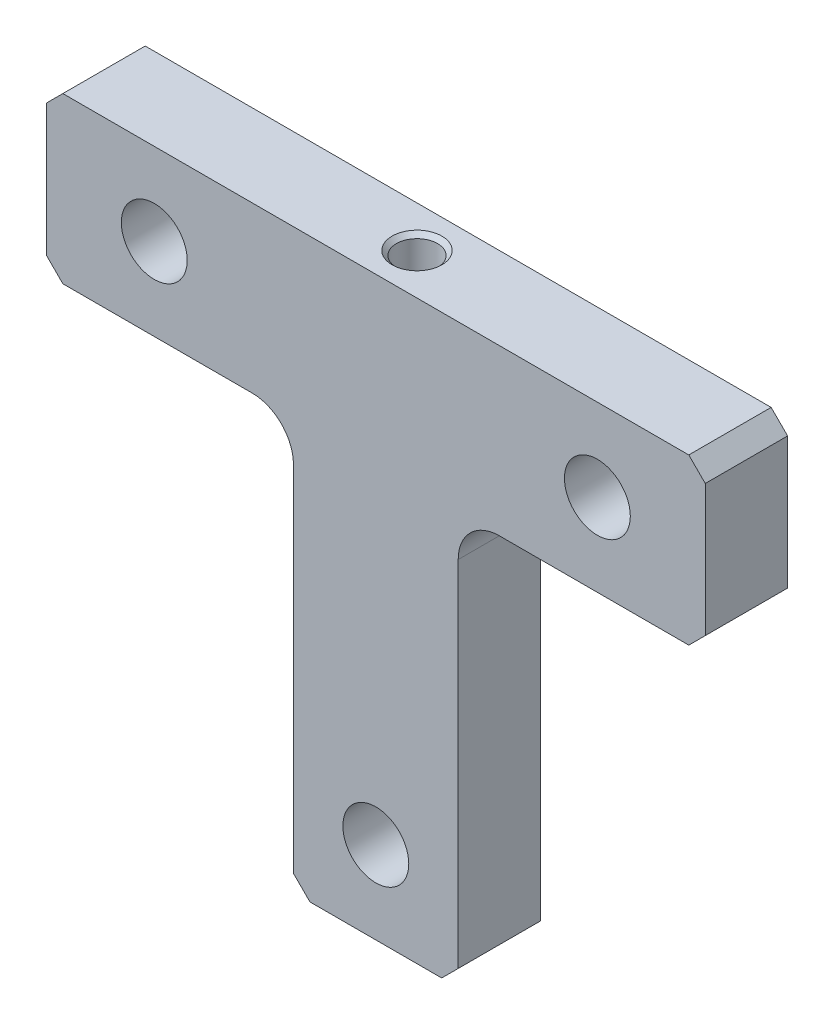
from build123d import *

# Parameters (mm, degrees)
PROFILE_SHAPE_DEPTH            = 5
SKETCH2_R                      = 4
LOWER_HOLE_DEPTH               = 11
SKETCH3_R                      = 4
UPPER_HOLE_RIGHT_DEPTH         = 11
M6_TAPPED_HOLE_TOP_D           = 5
M6_TAPPED_HOLE_TOP_DEPTH       = 15
M6_TAPPED_HOLE_TOP_CSINK_D     = 6.05
M6_TAPPED_HOLE_TOP_CSINK_ANGLE = 90
M6_TAPPED_HOLE_TOP_TIP         = 1.502151548
EXTERNAL_EDGES_SIZE            = 2
INTERNAL_EDGES_R               = 5


with BuildPart() as part:
    # Sketch1 → Profile Shape (new body, symmetric)
    with BuildSketch(Plane.XY):
        Polygon((-10, -10), (-10, 40), (-40, 40), (-40, 60), (40, 60), (40, 40), (10, 40), (10, -10), align=None)
    extrude(amount=PROFILE_SHAPE_DEPTH, both=True)

    # Sketch2 → Lower Hole (cut, through all)
    with BuildSketch(Plane.XY.offset(5)):
        Circle(SKETCH2_R)
    extrude(amount=-LOWER_HOLE_DEPTH, mode=Mode.SUBTRACT)

    # Sketch3 → Upper Hole Right (cut, through all)
    with BuildSketch(Plane.XY.offset(5)):
        with Locations((26.9, 50)):
            Circle(SKETCH3_R)
    upper_hole_right = extrude(amount=-UPPER_HOLE_RIGHT_DEPTH, mode=Mode.SUBTRACT)

    # Upper Hole Left: Upper Hole Right across plane
    add(upper_hole_right.mirror(Plane(origin=(0, 0, 0), x_dir=(0, 0, 1), z_dir=(1, 0, 0))), mode=Mode.SUBTRACT)

    # M6 Tapped Hole Top
    with Locations(Plane(origin=(0, 60, 0), x_dir=(1, 0, 0), z_dir=(0, 1, 0))):
        with Locations((0, 0)):
            CounterSinkHole(M6_TAPPED_HOLE_TOP_D / 2, M6_TAPPED_HOLE_TOP_CSINK_D / 2, depth=M6_TAPPED_HOLE_TOP_DEPTH, counter_sink_angle=M6_TAPPED_HOLE_TOP_CSINK_ANGLE)
            with Locations((0, 0, -(M6_TAPPED_HOLE_TOP_DEPTH + M6_TAPPED_HOLE_TOP_TIP / 2))):  # 118° drill point
                Cone(0, M6_TAPPED_HOLE_TOP_D / 2, M6_TAPPED_HOLE_TOP_TIP, mode=Mode.SUBTRACT)

    # External Edges
    external_edges_edges = [part.edges().sort_by_distance(p)[0] for p in [
        (-10, -10, 0),
        (-40, 40, 0),
        (-40, 60, 0),
        (40, 60, 0),
        (40, 40, 0),
        (10, -10, 0),
    ]]
    chamfer(external_edges_edges, length=EXTERNAL_EDGES_SIZE)

    # Internal Edges
    internal_edges_edges = [part.edges().sort_by_distance(p)[0] for p in [
        (-10, 40, 0),
        (10, 40, 0),
    ]]
    fillet(internal_edges_edges, radius=INTERNAL_EDGES_R)


solid = part.part
